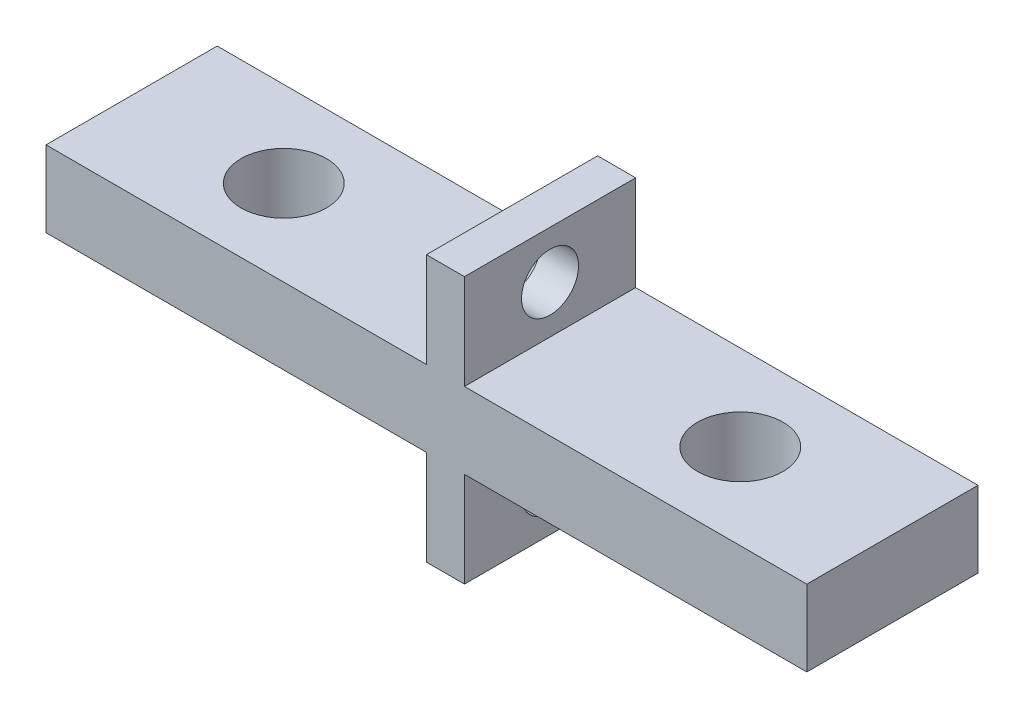
from build123d import *

# Parameters (mm, degrees)
SKETCH1_W                 = 40
SKETCH1_H                 = 9
BOSS_EXTRUDE1_DEPTH       = 4
F_8_CLEARANCE_HOLE1_D     = 4.4958
F_8_CLEARANCE_HOLE1_DEPTH = 17
F_8_CLEARANCE_HOLE1_TIP   = 1.350674586
SKETCH5_W                 = 2
SKETCH5_H                 = 9
BOSS_EXTRUDE2_DEPTH       = 5
BOSS_EXTRUDE2_DEPTH_BACK  = 9
SKETCH6_R                 = 1.5
CUT_EXTRUDE1_DEPTH        = 2


with BuildPart() as part:
    # Sketch1 → Boss-Extrude1 (new body)
    with BuildSketch(Plane(origin=(0, 0, 0), x_dir=(1, 0, 0), z_dir=(0, 1, 0))):
        with Locations((12.773632998, 0.813559322)):
            Rectangle(SKETCH1_W, SKETCH1_H)
    extrude(amount=BOSS_EXTRUDE1_DEPTH)

    # #8 Clearance Hole1
    with Locations(Plane(origin=(0.773632998, 4, -0.813559322), x_dir=(0, 0, 1), z_dir=(0, 1, 0))):
        with Locations((0, 0), (0, 24)):
            Hole(F_8_CLEARANCE_HOLE1_D / 2, depth=F_8_CLEARANCE_HOLE1_DEPTH)
            with Locations((0, 0, -(F_8_CLEARANCE_HOLE1_DEPTH + F_8_CLEARANCE_HOLE1_TIP / 2))):  # 118° drill point
                Cone(0, F_8_CLEARANCE_HOLE1_D / 2, F_8_CLEARANCE_HOLE1_TIP, mode=Mode.SUBTRACT)

    # Sketch5 → Boss-Extrude2 (add, two sides)
    with BuildSketch(Plane(origin=(0, 4, 0), x_dir=(1, 0, 0), z_dir=(0, 1, 0))) as boss_extrude2_sk:
        with Locations((13.773632998, 0.813559322)):
            Rectangle(SKETCH5_W, SKETCH5_H)
    extrude(amount=BOSS_EXTRUDE2_DEPTH)
    extrude(boss_extrude2_sk.sketch, amount=-BOSS_EXTRUDE2_DEPTH_BACK)

    # Sketch6 → Cut-Extrude1 (cut)
    with BuildSketch(Plane.ZY.offset(-12.773632998)):
        with Locations((-0.813559322, 6.5)):
            Circle(SKETCH6_R)
        with Locations((-0.813559322, -2.5)):
            Circle(SKETCH6_R)
    extrude(amount=-CUT_EXTRUDE1_DEPTH, mode=Mode.SUBTRACT)


solid = part.part
